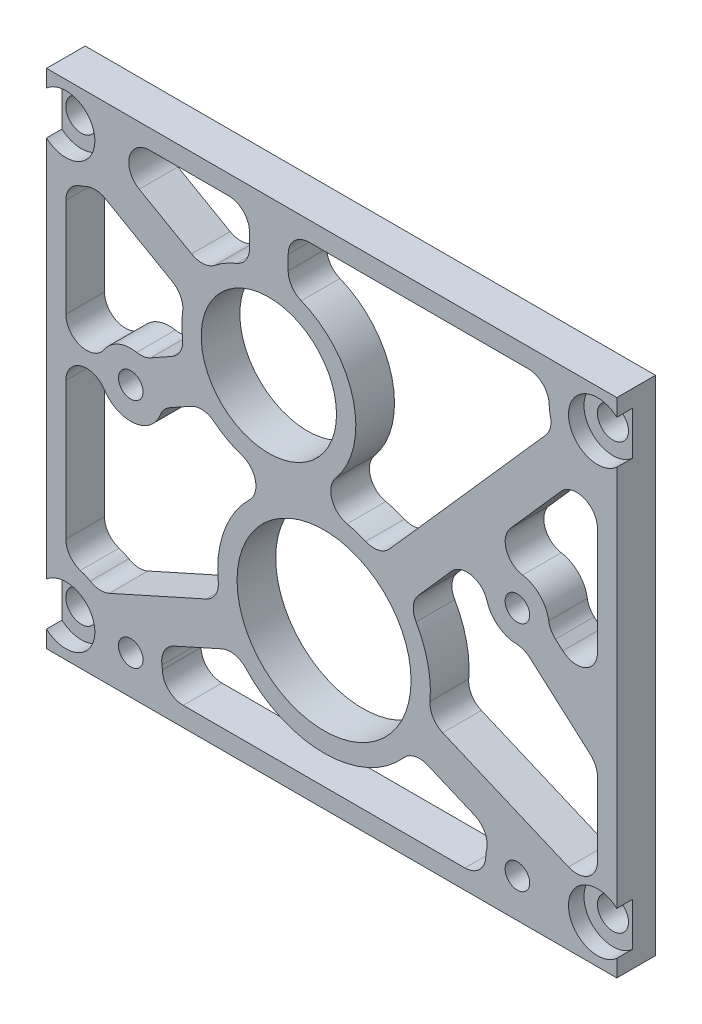
from build123d import *

# Parameters (mm, degrees)
SKETCH1_W                                           = 93.6625
SKETCH1_H                                           = 82.55
SKETCH1_R                                           = 11.1125
SKETCH1_R_2                                         = 14.2875
BOSS_EXTRUDE1_DEPTH                                 = 6.35
CBORE_FOR_10_BINDING_HEAD_MACHINE_SCREW_D           = 5.1054
CBORE_FOR_10_BINDING_HEAD_MACHINE_SCREW_CBORE_D     = 9.525
CBORE_FOR_10_BINDING_HEAD_MACHINE_SCREW_CBORE_DEPTH = 2.54
F_10_32_TAPPED_HOLE1_D                              = 4.0386
CUT_EXTRUDE1_DEPTH                                  = 7.35
FILLET1_R                                           = 3.429


with BuildPart() as part:
    # Sketch1 → Boss-Extrude1 (new body)
    with BuildSketch(Plane.XY):
        with Locations((10.31875, -15.875)):
            Rectangle(SKETCH1_W, SKETCH1_H)
        Circle(SKETCH1_R, mode=Mode.SUBTRACT)
        with Locations((9.069614104, -31.75)):
            Circle(SKETCH1_R_2, mode=Mode.SUBTRACT)
    extrude(amount=BOSS_EXTRUDE1_DEPTH)

    # CBORE for #10 Binding Head Machine Screw1 (through all)
    with Locations(Plane.XY.offset(6.35)):
        with Locations((-33.3375, 19.05), (53.975, 19.05), (-33.3375, -50.8), (53.975, -50.8)):
            CounterBoreHole(CBORE_FOR_10_BINDING_HEAD_MACHINE_SCREW_D / 2, CBORE_FOR_10_BINDING_HEAD_MACHINE_SCREW_CBORE_D / 2, CBORE_FOR_10_BINDING_HEAD_MACHINE_SCREW_CBORE_DEPTH)

    # #10-32 Tapped Hole1 (through all)
    with Locations(Plane.XY.offset(6.35)):
        with Locations((-22.680385896, -12.7), (-22.680385896, -50.8), (40.819614104, -12.7), (40.819614104, -50.8)):
            Hole(F_10_32_TAPPED_HOLE1_D / 2)

    # Sketch4 → Cut-Extrude1 (cut, through all)
    with BuildSketch(Plane.XY):
        with BuildLine():
            Line((-18.569409431, -53.975), (36.70863764, -53.975))
            ThreePointArc((36.70863764, -53.975), (35.636461118, -50.459885882), (37.158783689, -47.115020602))
            Line((37.158783689, -47.115020602), (23.637471172, -41.378937985))
            ThreePointArc((23.637471172, -41.378937985), (9.2528656, -49.211538453), (-5.292953374, -41.682550613))
            Line((-5.292953374, -41.682550613), (-18.557083214, -47.641024298))
            ThreePointArc((-18.557083214, -47.641024298), (-17.486095731, -50.810108335), (-18.569409431, -53.975))
        make_face()
        with BuildLine():
            Line((-33.3375, 11.1125), (-33.3375, -7.997270007))
            ThreePointArc((-33.3375, -7.997270007), (-30.883785524, -11.284648772), (-27.034286733, -9.867280461))
            ThreePointArc((-27.034286733, -9.867280461), (-24.193758641, -7.731050873), (-20.644686909, -7.921225876))
            Line((-20.644686909, -7.921225876), (-13.705685479, -4.035695949))
            ThreePointArc((-13.705685479, -4.035695949), (-14.287365074, 0.062092554), (-13.670090339, 4.154670429))
            Line((-13.670090339, 4.154670429), (-28.596412131, 12.683997167))
            ThreePointArc((-28.596412131, 12.683997167), (-30.840125502, 11.515610385), (-33.3375, 11.1125))
        make_face()
        with BuildLine():
            Line((46.700161084, 22.225), (3.175, 22.225))
            Line((3.175, 22.225), (3.175, 13.930255965))
            ThreePointArc((3.175, 13.930255965), (13.537348624, 4.568681263), (10.966843182, -9.157565554))
            ThreePointArc((10.966843182, -9.157565554), (10.352981582, -12.460889523), (12.855479291, -14.702826303))
            ThreePointArc((12.855479291, -14.702826303), (15.543443695, -15.531848543), (18.063427807, -16.78169277))
            Line((18.063427807, -16.78169277), (46.778040385, 15.702212888))
            ThreePointArc((46.778040385, 15.702212888), (46.038065698, 18.955236384), (46.700161084, 22.225))
        make_face()
        with BuildLine():
            Line((53.975, -42.17165131), (53.975, -28.566526704))
            Line((53.975, -28.566526704), (41.796913331, -17.801532977))
            ThreePointArc((41.796913331, -17.801532977), (38.120534528, -17.137986247), (35.84028076, -14.178848178))
            ThreePointArc((35.84028076, -14.178848178), (33.293441059, -11.80696069), (29.984051116, -12.884077639))
            Line((29.984051116, -12.884077639), (22.821092939, -20.987298848))
            ThreePointArc((22.821092939, -20.987298848), (26.100298189, -27.89063401), (26.117377775, -35.533207642))
            Line((26.117377775, -35.533207642), (49.206850434, -45.328345695))
            ThreePointArc((49.206850434, -45.328345695), (52.438894231, -45.030845677), (53.975, -42.17165131))
        make_face()
        with BuildLine():
            Line((-3.175, 13.930255965), (-3.175, 22.225))
            Line((-3.175, 22.225), (-19.582212458, 22.225))
            ThreePointArc((-19.582212458, 22.225), (-22.896339753, 19.67611435), (-21.283472877, 15.818794266))
            Line((-21.283472877, 15.818794266), (-10.51960808, 9.668014382))
            ThreePointArc((-10.51960808, 9.668014382), (-7.171279415, 12.357402955), (-3.175, 13.930255965))
        make_face()
        with BuildLine():
            Line((47.976860828, 7.470601764), (39.67259297, -1.923745903))
            ThreePointArc((39.67259297, -1.923745903), (39.009735491, -5.340303041), (41.676236015, -7.576822139))
            ThreePointArc((41.676236015, -7.576822139), (44.892833891, -9.476704627), (46.002519409, -13.043867844))
            Line((46.002519409, -13.043867844), (53.975, -20.091255983))
            Line((53.975, -20.091255983), (53.975, 5.199574482))
            ThreePointArc((53.975, 5.199574482), (51.760179307, 8.406412428), (47.976860828, 7.470601764))
        make_face()
        with BuildLine():
            Line((-28.002497029, -44.922785562), (-7.89499723, -35.890153201))
            ThreePointArc((-7.89499723, -35.890153201), (-7.721475523, -26.954354539), (-3.149535541, -19.27477302))
            ThreePointArc((-3.149535541, -19.27477302), (-2.208851914, -16.049266917), (-4.474945322, -13.56862265))
            ThreePointArc((-4.474945322, -13.56862265), (-7.798895494, -11.971210688), (-10.60324305, -9.576214966))
            Line((-10.60324305, -9.576214966), (-17.54224448, -13.461744893))
            ThreePointArc((-17.54224448, -13.461744893), (-21.573140522, -17.774914795), (-27.034286733, -15.532719539))
            ThreePointArc((-27.034286733, -15.532719539), (-30.883785524, -14.115351228), (-33.3375, -17.402729993))
            Line((-33.3375, -17.402729993), (-33.3375, -42.8625))
            ThreePointArc((-33.3375, -42.8625), (-30.47799684, -43.395464368), (-28.002497029, -44.922785562))
        make_face()
    extrude(amount=CUT_EXTRUDE1_DEPTH, mode=Mode.SUBTRACT)

    # Fillet1
    fillet1_edges = [part.edges().sort_by_distance(p)[0] for p in [
        (-33.3375, -42.8625, 3.175),
        (-28.002497029, -44.922785562, 3.175),
        (-7.89499723, -35.890153201, 3.175),
        (-10.60324305, -9.576214966, 3.175),
        (-17.54224448, -13.461744893, 3.175),
        (46.002519409, -13.043867844, 3.175),
        (53.975, -20.091255983, 3.175),
        (-3.175, 22.225, 3.175),
        (-10.51960808, 9.668014382, 3.175),
        (-3.175, 13.930255965, 3.175),
        (36.70863764, -53.975, 3.175),
        (37.158783689, -47.115020602, 3.175),
        (23.637471172, -41.378937985, 3.175),
        (-5.292953374, -41.682550613, 3.175),
        (-18.557083214, -47.641024298, 3.175),
        (-18.569409431, -53.975, 3.175),
        (46.778040385, 15.702212888, 3.175),
        (46.700161084, 22.225, 3.175),
        (3.175, 22.225, 3.175),
        (3.175, 13.930255965, 3.175),
        (18.063427807, -16.78169277, 3.175),
        (22.821092939, -20.987298848, 3.175),
        (26.117377775, -35.533207642, 3.175),
        (53.975, -28.566526704, 3.175),
        (41.796913331, -17.801532977, 3.175),
        (-28.596412131, 12.683997167, 3.175),
        (-33.3375, 11.1125, 3.175),
        (-20.644686909, -7.921225876, 3.175),
        (-13.705685479, -4.035695949, 3.175),
        (-13.670090339, 4.154670429, 3.175),
    ]]
    fillet(fillet1_edges, radius=FILLET1_R)


solid = part.part
